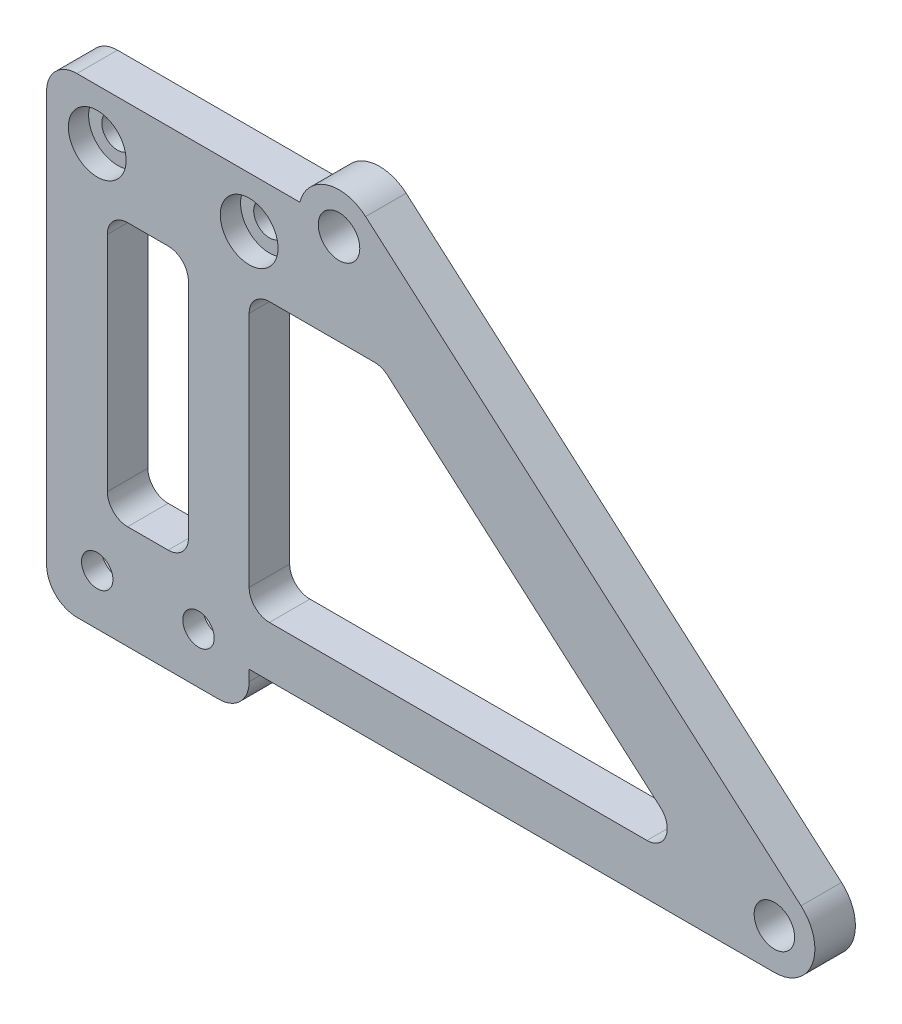
from build123d import *

# Parameters (mm, degrees)
SKETCH1_R           = 1.55
SKETCH1_R_2         = 2.05
BOSS_EXTRUDE1_DEPTH = 4
SKETCH2_R           = 2
BOSS_EXTRUDE2_DEPTH = 4
SKETCH3_W           = 20
SKETCH3_H           = 4
BOSS_EXTRUDE3_DEPTH = 36.5
SKETCH4_R           = 1.55
CUT_EXTRUDE1_DEPTH  = 5
CUT_EXTRUDE2_DEPTH  = 2
BOSS_EXTRUDE4_DEPTH = 4
FILLET1_R           = 2
FILLET2_R           = 3
SKETCH7_W           = 8
SKETCH7_H           = 26
CUT_EXTRUDE3_DEPTH  = 10
FILLET3_R           = 2
SKETCH8_R           = 2.85
CUT_EXTRUDE4_DEPTH  = 2


with BuildPart() as part:
    # Sketch1 → Boss-Extrude1 (new body)
    with BuildSketch(Plane.XY):
        with BuildLine():
            Line((-25, -35.5), (0, -35.5))
            Line((0, -35.5), (7.872983346, -35.5))
            Line((7.872983346, -35.5), (7.872983346, -26.5))
            ThreePointArc((7.872983346, -26.5), (4.377000516, -22.531881215), (0, -25.5))
            Line((0, -25.5), (-25, -25.5))
            Line((-25, -25.5), (-25, -35.5))
        make_face()
        with Locations((-20, -30.5)):
            Circle(SKETCH1_R, mode=Mode.SUBTRACT)
        with Locations((-5, -30.5)):
            Circle(SKETCH1_R, mode=Mode.SUBTRACT)
        with Locations((3.872983346, -26.5)):
            Circle(SKETCH1_R_2, mode=Mode.SUBTRACT)
    extrude(amount=BOSS_EXTRUDE1_DEPTH)

    # Sketch2 → Boss-Extrude2 (add)
    with BuildSketch(Plane.XY.offset(4)):
        with BuildLine():
            Line((7.872983346, -35.5), (7.872983346, -26.5))
            ThreePointArc((7.872983346, -26.5), (7.513600322, -24.842921839), (6.50002933, -23.483606557))
            Line((6.50002933, -23.483606557), (49.483635887, -60.919011822))
            ThreePointArc((49.483635887, -60.919011822), (49.872983346, -66.562451248), (44.22954392, -66.951798707))
            Line((44.22954392, -66.951798707), (8.116358245, -35.5))
            Line((8.116358245, -35.5), (7.872983346, -35.5))
        make_face()
        with Locations((46.856589904, -63.935405265)):
            Circle(SKETCH2_R, mode=Mode.SUBTRACT)
    extrude(amount=-BOSS_EXTRUDE2_DEPTH)

    # Sketch3 → Boss-Extrude3 (add)
    with BuildSketch(Plane.XZ.offset(35.5)):
        with Locations((-15, 2)):
            Rectangle(SKETCH3_W, SKETCH3_H)
    extrude(amount=BOSS_EXTRUDE3_DEPTH)

    # Sketch4 → Cut-Extrude1 (cut, through all)
    with BuildSketch(Plane.XY.offset(4)):
        with Locations((-20, -67)):
            Circle(SKETCH4_R)
        with Locations((-10, -67)):
            Circle(SKETCH4_R)
    extrude(amount=-CUT_EXTRUDE1_DEPTH, mode=Mode.SUBTRACT)

    # Sketch5 → Cut-Extrude2 (cut)
    with BuildSketch(Plane(origin=(0, 0, 0), x_dir=(-1, 0, 0), z_dir=(0, 0, -1))):
        Polygon((22.85, -68.645448267), (22.85, -65.354551733), (20, -63.709103466), (17.15, -65.354551733), (17.15, -68.645448267), (20, -70.290896534), align=None)
        Polygon((12.85, -68.645448267), (12.85, -65.354551733), (10, -63.709103466), (7.15, -65.354551733), (7.15, -68.645448267), (10, -70.290896534), align=None)
    extrude(amount=-CUT_EXTRUDE2_DEPTH, mode=Mode.SUBTRACT)

    # Sketch6 → Boss-Extrude4 (add)
    with BuildSketch(Plane(origin=(0, 0, 0), x_dir=(-1, 0, 0), z_dir=(0, 0, -1))):
        with BuildLine():
            ThreePointArc((-44.22954392, -66.951798707), (-45.454016157, -67.681441421), (-46.856589904, -67.935405265))
            Line((-46.856589904, -67.935405265), (5, -67.935405265))
            Line((5, -67.935405265), (5, -62.935405265))
            Line((5, -62.935405265), (-39.617891547, -62.935405265))
            Line((-39.617891547, -62.935405265), (-44.22954392, -66.951798707))
        make_face()
    extrude(amount=-BOSS_EXTRUDE4_DEPTH)

    # Fillet1
    fillet1_edges = [part.edges().sort_by_distance(p)[0] for p in [
        (39.617891547, -62.935405265, 2),
        (-5, -62.935405265, 2),
        (8.116358245, -35.5, 2),
        (-5, -35.5, 2),
    ]]
    fillet(fillet1_edges, radius=FILLET1_R)

    # Fillet2
    fillet2_edges = [part.edges().sort_by_distance(p)[0] for p in [
        (-25, -25.5, 2),
        (-5, -72, 2),
        (-25, -72, 2),
    ]]
    fillet(fillet2_edges, radius=FILLET2_R)

    # Sketch7 → Cut-Extrude3 (cut)
    with BuildSketch(Plane(origin=(0, 0, 0), x_dir=(-1, 0, 0), z_dir=(0, 0, -1))):
        with Locations((15, -48.75)):
            Rectangle(SKETCH7_W, SKETCH7_H)
    extrude(amount=-CUT_EXTRUDE3_DEPTH, mode=Mode.SUBTRACT)

    # Fillet3
    fillet3_edges = [part.edges().sort_by_distance(p)[0] for p in [
        (-11, -61.75, 2),
        (-11, -35.75, 2),
        (-19, -35.75, 2),
        (-19, -61.75, 2),
    ]]
    fillet(fillet3_edges, radius=FILLET3_R)

    # Sketch8 → Cut-Extrude4 (cut)
    with BuildSketch(Plane.XY.offset(4)):
        with Locations((-20, -30.5)):
            Circle(SKETCH8_R)
        with Locations((-5, -30.5)):
            Circle(SKETCH8_R)
    extrude(amount=-CUT_EXTRUDE4_DEPTH, mode=Mode.SUBTRACT)


solid = part.part
